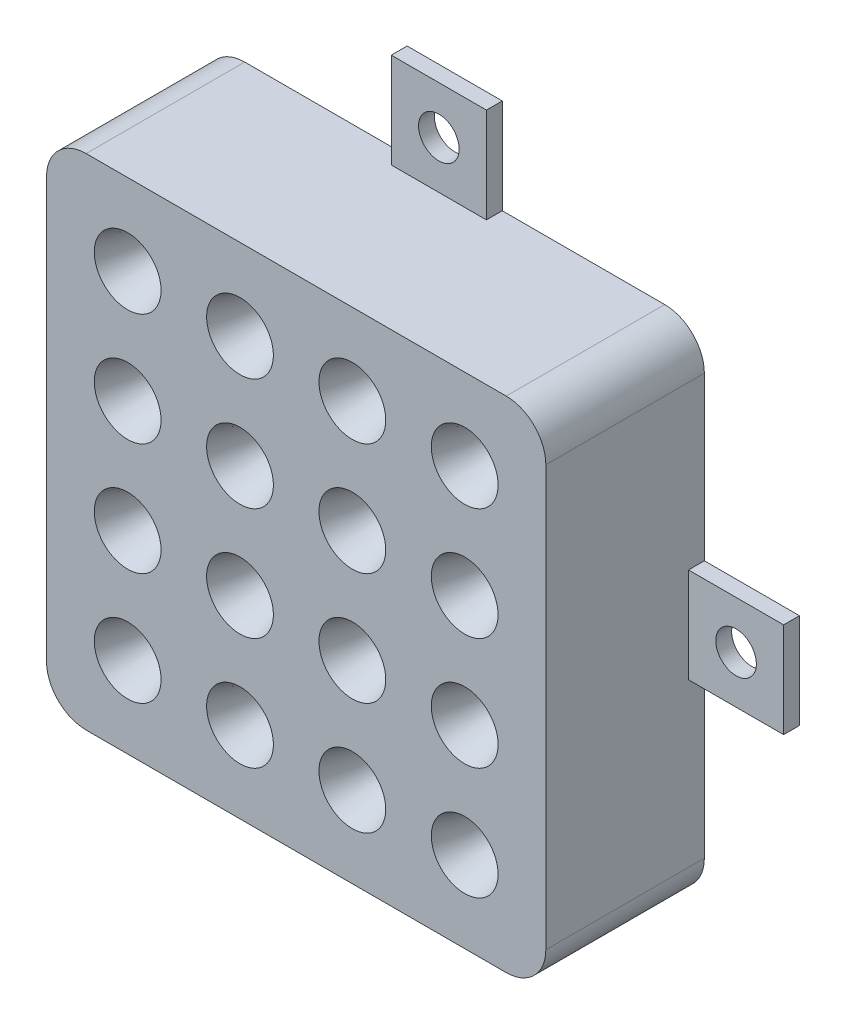
from build123d import *

# Parameters (mm, degrees)
SKETCH1_W           = 40
SKETCH1_H           = 40
BOSS_EXTRUDE1_DEPTH = 12.7
SKETCH2_R           = 2.67558437
CUT_EXTRUDE1_DEPTH  = 8
CUT_EXTRUDE1_TAPER  = 17.5
FILLET1_R           = 3.175
SKETCH3_W           = 7.62
SKETCH3_H           = 1.27
BOSS_EXTRUDE2_DEPTH = 7.62
SKETCH4_W           = 1.27
SKETCH4_H           = 7.62
BOSS_EXTRUDE3_DEPTH = 7.62
SKETCH5_W           = 1.27
SKETCH5_H           = 7.62
BOSS_EXTRUDE4_DEPTH = 7.62
SKETCH6_W           = 7.62
SKETCH6_H           = 1.27
BOSS_EXTRUDE5_DEPTH = 7.62
SKETCH7_R           = 1.6256
CUT_EXTRUDE2_DEPTH  = 7.62


with BuildPart() as part:
    # Sketch1 → Boss-Extrude1 (new body)
    with BuildSketch(Plane.XY):
        with Locations((-32.473746891, -5.437780853)):
            Rectangle(SKETCH1_W, SKETCH1_H)
    extrude(amount=BOSS_EXTRUDE1_DEPTH)

    # Sketch2 → Cut-Extrude1 (cut)
    with BuildSketch(Plane.XY.offset(12.7)):
        with Locations((-45.973746891, 8.062219147)):
            Circle(SKETCH2_R)
        with Locations((-36.973746891, 8.062219147)):
            Circle(SKETCH2_R)
        with Locations((-27.973746891, 8.062219147)):
            Circle(SKETCH2_R)
        with Locations((-18.973746891, 8.062219147)):
            Circle(SKETCH2_R)
        with Locations((-45.973746891, -0.937780853)):
            Circle(SKETCH2_R)
        with Locations((-36.973746891, -0.937780853)):
            Circle(SKETCH2_R)
        with Locations((-27.973746891, -0.937780853)):
            Circle(SKETCH2_R)
        with Locations((-18.973746891, -0.937780853)):
            Circle(SKETCH2_R)
        with Locations((-45.973746891, -9.937780853)):
            Circle(SKETCH2_R)
        with Locations((-36.973746891, -9.937780853)):
            Circle(SKETCH2_R)
        with Locations((-27.973746891, -9.937780853)):
            Circle(SKETCH2_R)
        with Locations((-18.973746891, -9.937780853)):
            Circle(SKETCH2_R)
        with Locations((-45.973746891, -18.937780853)):
            Circle(SKETCH2_R)
        with Locations((-36.973746891, -18.937780853)):
            Circle(SKETCH2_R)
        with Locations((-27.973746891, -18.937780853)):
            Circle(SKETCH2_R)
        with Locations((-18.973746891, -18.937780853)):
            Circle(SKETCH2_R)
    extrude(amount=-CUT_EXTRUDE1_DEPTH, taper=CUT_EXTRUDE1_TAPER, mode=Mode.SUBTRACT)

    # Fillet1
    fillet1_edges = [part.edges().sort_by_distance(p)[0] for p in [
        (-52.473746891, 14.562219147, 6.35),
        (-12.473746891, 14.562219147, 6.35),
        (-12.473746891, -25.437780853, 6.35),
        (-52.473746891, -25.437780853, 6.35),
    ]]
    fillet(fillet1_edges, radius=FILLET1_R)

    # Sketch3 → Boss-Extrude2 (add)
    with BuildSketch(Plane(origin=(0, 14.562219147, 0), x_dir=(1, 0, 0), z_dir=(0, 1, 0))):
        with Locations((-32.473706891, -0.635)):
            Rectangle(SKETCH3_W, SKETCH3_H)
    extrude(amount=BOSS_EXTRUDE2_DEPTH)

    # Sketch4 → Boss-Extrude3 (add)
    with BuildSketch(Plane(origin=(-12.473746891, 0, 0), x_dir=(0, 0, -1), z_dir=(1, 0, 0))):
        with Locations((-0.635, -5.437820853)):
            Rectangle(SKETCH4_W, SKETCH4_H)
    extrude(amount=BOSS_EXTRUDE3_DEPTH)

    # Sketch5 → Boss-Extrude4 (add)
    with BuildSketch(Plane.ZY.offset(52.473746891)):
        with Locations((0.635, -5.437740853)):
            Rectangle(SKETCH5_W, SKETCH5_H)
    extrude(amount=BOSS_EXTRUDE4_DEPTH)

    # Sketch6 → Boss-Extrude5 (add)
    with BuildSketch(Plane.XZ.offset(25.437780853)):
        with Locations((-32.473786891, 0.635)):
            Rectangle(SKETCH6_W, SKETCH6_H)
    extrude(amount=BOSS_EXTRUDE5_DEPTH)

    # Sketch7 → Cut-Extrude2 (cut)
    with BuildSketch(Plane.XY.offset(1.27)):
        with Locations((-32.473786891, -29.247780853)):
            Circle(SKETCH7_R)
        with Locations((-56.283746891, -5.437740853)):
            Circle(SKETCH7_R)
        with Locations((-8.663746891, -5.437820853)):
            Circle(SKETCH7_R)
        with Locations((-32.473706891, 18.372219147)):
            Circle(SKETCH7_R)
    extrude(amount=-CUT_EXTRUDE2_DEPTH, mode=Mode.SUBTRACT)


solid = part.part
